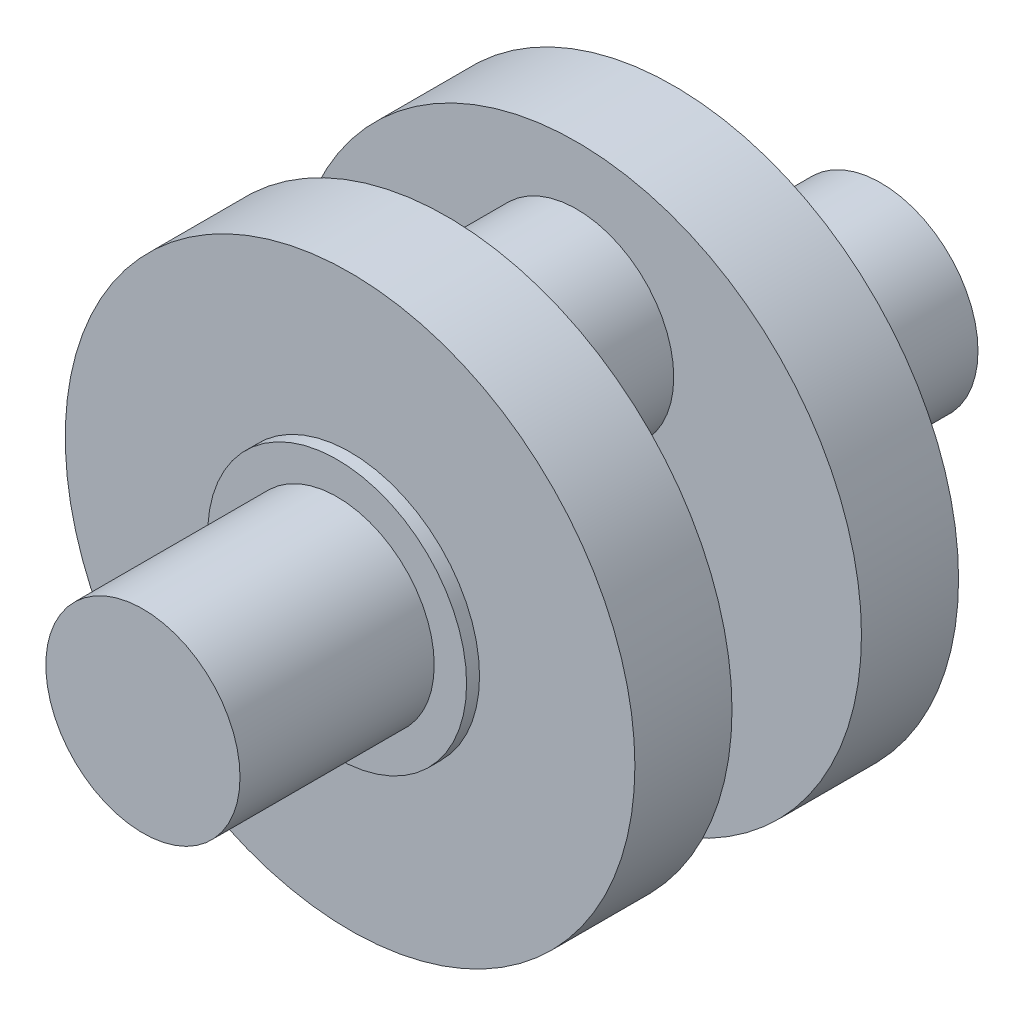
from build123d import *

# Parameters (mm, degrees)
SZKIC1_R                    = 15
DODANIE_WYCI_GNI_CIE1_DEPTH = 30
SZKIC2_R                    = 20
DODANIE_WYCI_GNI_CIE2_DEPTH = 2
DODANIE_WYCI_GNI_CIE3_START = -2
SZKIC3_R                    = 44
DODANIE_WYCI_GNI_CIE3_DEPTH = 15
DODANIE_WYCI_GNI_CIE4_START = -17
SZKIC4_R                    = 15
DODANIE_WYCI_GNI_CIE4_DEPTH = 10


with BuildPart() as part:
    # Szkic1 → Dodanie-wyciągnięcie1 (new body)
    with BuildSketch(Plane.XY):
        Circle(SZKIC1_R)
    extrude(amount=DODANIE_WYCI_GNI_CIE1_DEPTH)

    # Szkic2 → Dodanie-wyciągnięcie2 (add)
    with BuildSketch(Plane.XY):
        Circle(SZKIC2_R)
    extrude(amount=-DODANIE_WYCI_GNI_CIE2_DEPTH)

    # Szkic3 → Dodanie-wyciągnięcie3 (add)
    with BuildSketch(Plane.XY.offset(DODANIE_WYCI_GNI_CIE3_START)):
        Circle(SZKIC3_R)
    extrude(amount=-DODANIE_WYCI_GNI_CIE3_DEPTH)

    # Szkic4 → Dodanie-wyciągnięcie4 (add)
    with BuildSketch(Plane.XY.offset(DODANIE_WYCI_GNI_CIE4_START)):
        with Locations((0, 20)):
            Circle(SZKIC4_R)
    extrude(amount=-DODANIE_WYCI_GNI_CIE4_DEPTH)

    # Lustro2: part across plane


with BuildPart() as part_1:
    add(part.part)
    add(part.part.mirror(Plane(origin=(0, 20, -27), x_dir=(1, 0, 0), z_dir=(0, 0, 1))))


solid = part_1.part
